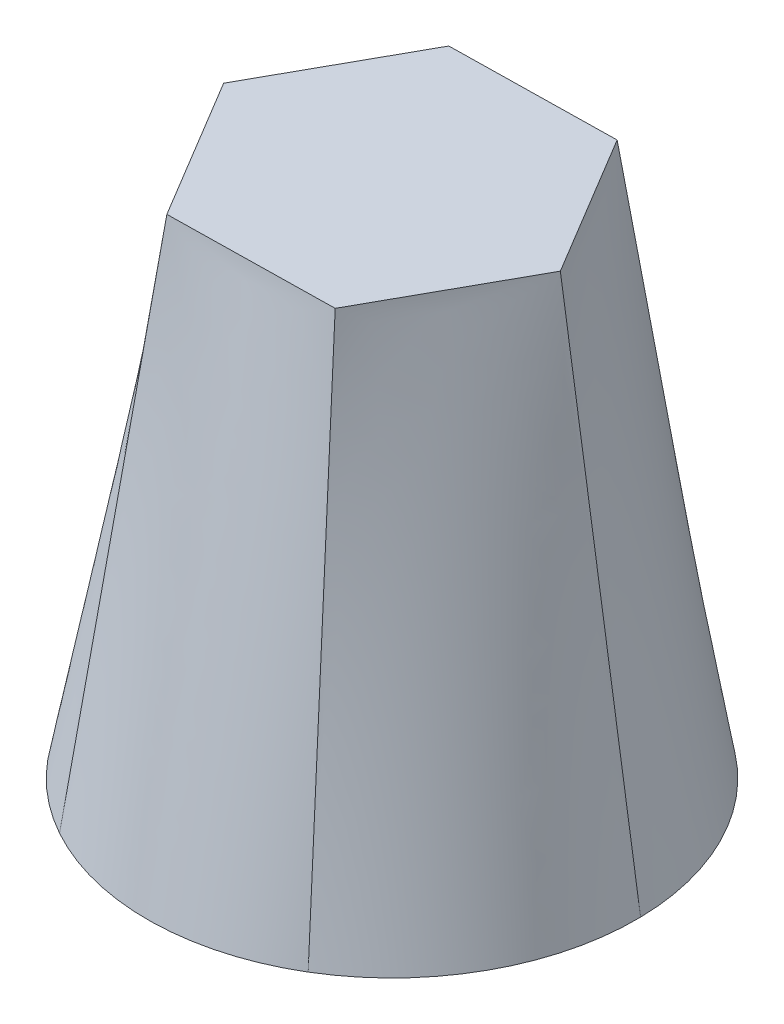
from build123d import *


with BuildPart() as part:
    # Sketch2 → Loft2 section 0
    with BuildSketch(Plane(origin=(0, 140, 0), x_dir=(1, 0, 0), z_dir=(0, 1, 0))):
        Polygon((22.906863075, -38.178105125), (44.516640444, 0.748872781), (21.609777369, 38.926977906), (-22.906863075, 38.178105125), (-44.516640444, -0.748872781), (-21.609777369, -38.926977906), align=None)
    # Sketch1 for Loft2 → Loft2 section 1
    with BuildSketch(Plane(origin=(0, 0, 0), x_dir=(1, 0, 0), z_dir=(0, 1, 0))):
        with BuildLine():
            # circular arc as an exact rational Bezier (weights 1, cos(half-angle), 1)
            Bezier((33.823020911, -56.371701518), (66.369237958, -36.843971291), (65.730836025, 1.105744582), weights=[1, 0.866025404, 1])
            Bezier((65.730836025, 1.105744582), (65.092434092, 39.055460455), (31.907815114, 57.477446101), weights=[1, 0.866025404, 1])
            Bezier((31.907815114, 57.477446101), (-1.276803865, 75.899431746), (-33.823020911, 56.371701518), weights=[1, 0.866025404, 1])
            Bezier((-33.823020911, 56.371701518), (-66.369237958, 36.843971291), (-65.730836025, -1.105744582), weights=[1, 0.866025404, 1])
            Bezier((-65.730836025, -1.105744582), (-65.092434092, -39.055460455), (-31.907815114, -57.477446101), weights=[1, 0.866025404, 1])
            Bezier((-31.907815114, -57.477446101), (1.276803865, -75.899431746), (33.823020911, -56.371701518), weights=[1, 0.866025404, 1])
        make_face()
    loft()


solid = part.part
